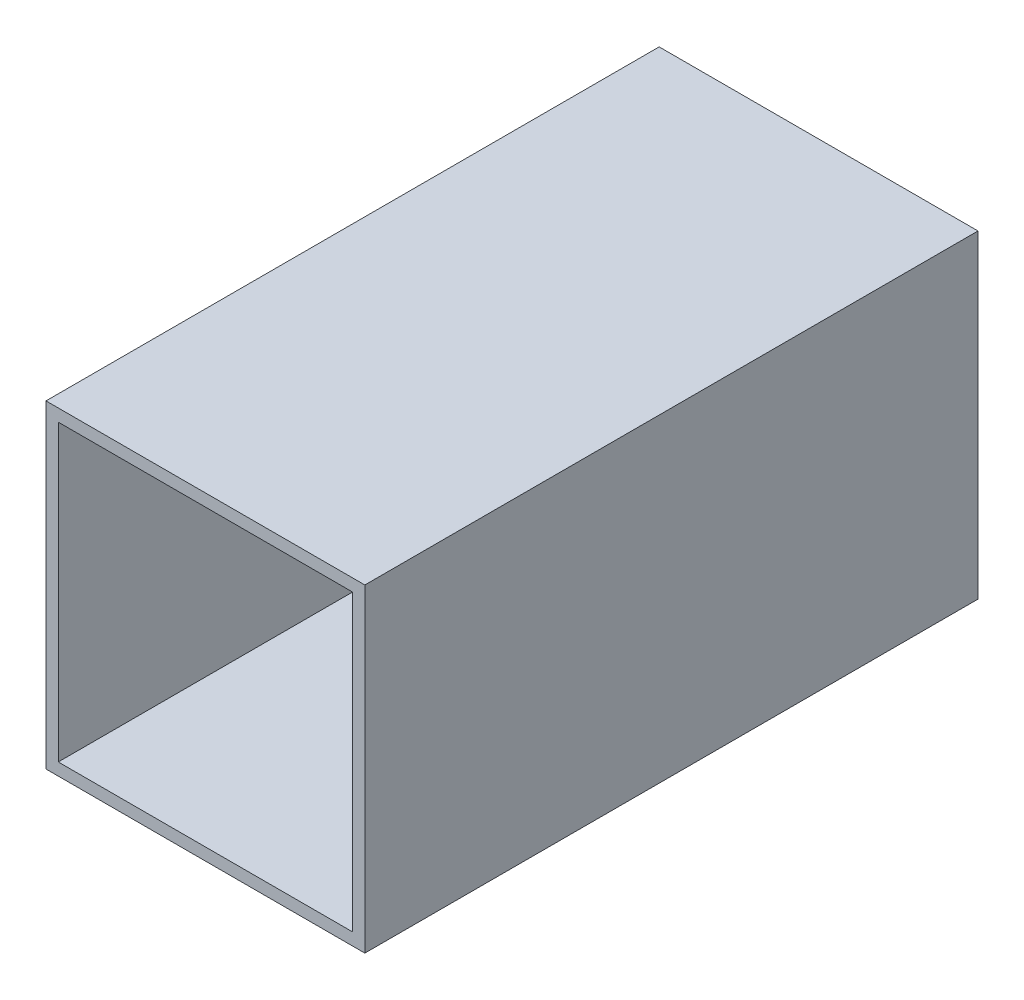
from build123d import *

# Parameters (mm, degrees)
SKETCH1_W           = 79.248
SKETCH1_H           = 79.248
SKETCH1_W_2         = 73.152
SKETCH1_H_2         = 73.152
BOSS_EXTRUDE1_DEPTH = 152.4


with BuildPart() as part:
    # Sketch1 → Boss-Extrude1 (new body)
    with BuildSketch(Plane.XY):
        Rectangle(SKETCH1_W, SKETCH1_H)
        Rectangle(SKETCH1_W_2, SKETCH1_H_2, mode=Mode.SUBTRACT)
    extrude(amount=BOSS_EXTRUDE1_DEPTH)


solid = part.part
